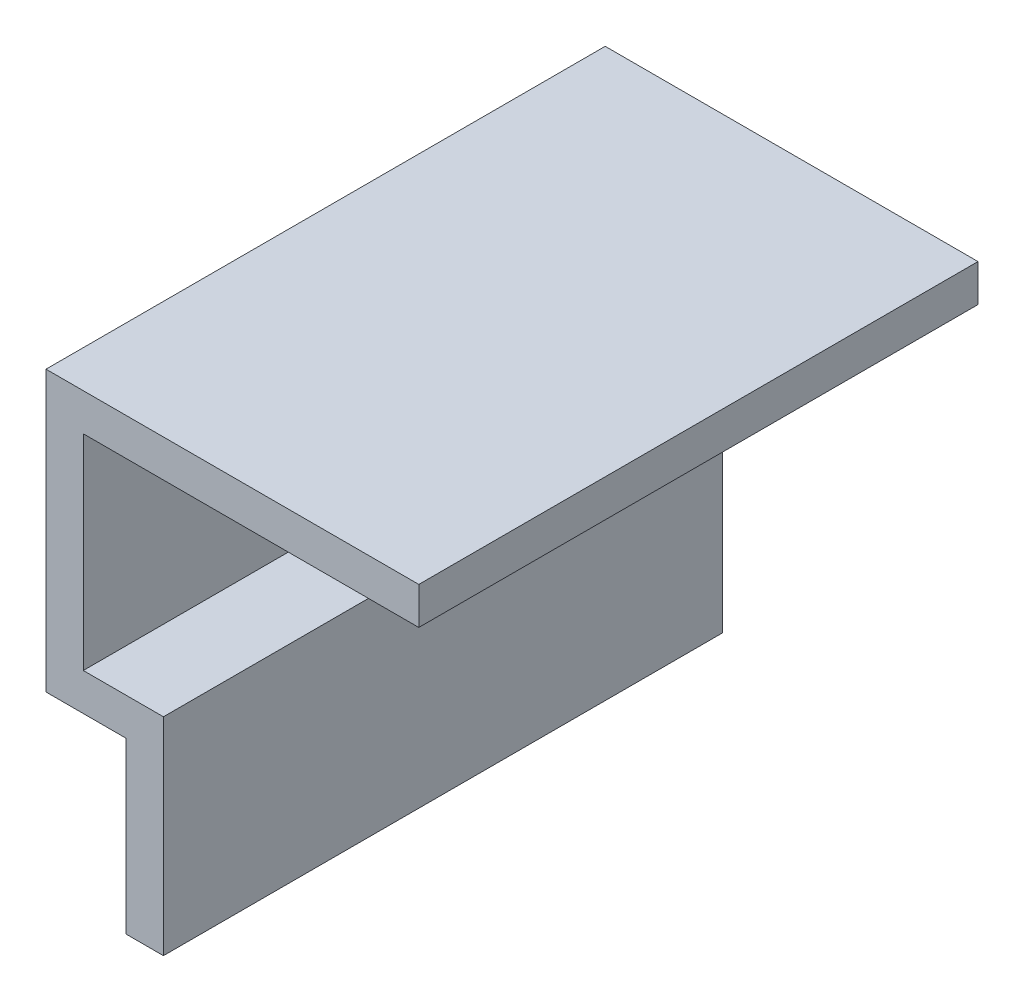
from build123d import *

# Parameters (mm, degrees)
EXTRUDE_1_DEPTH = 30


with BuildPart() as part:
    # 草图1 → 凸台-拉伸1 (new body)
    with BuildSketch(Plane.XY):
        Polygon((-28.950221265, -18.190684527), (-28.950221265, -9.090684527), (-33.250221265, -9.090684527), (-33.250221265, 5.909315473), (-13.250221265, 5.909315473), (-13.250221265, 3.909315473), (-31.250221265, 3.909315473), (-31.250221265, -7.090684527), (-26.950221265, -7.090684527), (-26.950221265, -18.190684527), align=None)
    extrude(amount=EXTRUDE_1_DEPTH)


solid = part.part
